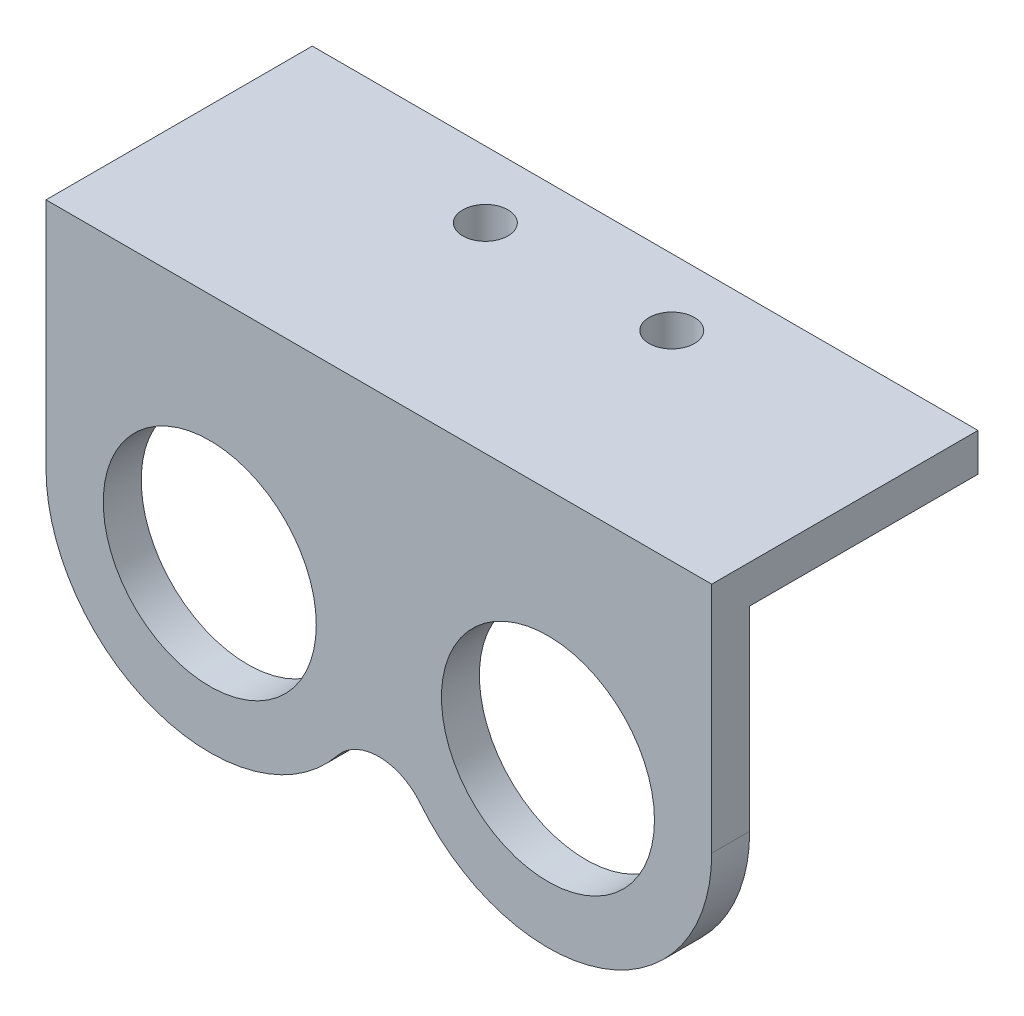
from build123d import *

# Parameters (mm, degrees)
SKETCH2_R           = 8
BOSS_EXTRUDE1_DEPTH = 2.85
SKETCH3_W           = 17.15
SKETCH3_H           = 2.85
BOSS_EXTRUDE2_DEPTH = 50
SKETCH4_R           = 1.7
CUT_EXTRUDE1_DEPTH  = 2.85


with BuildPart() as part:
    # Sketch2 → Boss-Extrude1 (new body)
    with BuildSketch(Plane.XY):
        with BuildLine():
            Line((-25, 17.5), (-25, 0))
            ThreePointArc((-25, 0), (-16.787403964, -11.60099689), (-3.116564417, -7.710237508))
            ThreePointArc((-3.116564417, -7.710237508), (0, -6.21763182), (3.116564417, -7.710237508))
            ThreePointArc((3.116564417, -7.710237508), (16.787403964, -11.60099689), (25, 0))
            Line((25, 0), (25, 17.5))
            Line((25, 17.5), (-25, 17.5))
        make_face()
        with Locations((12.7, 0)):
            Circle(SKETCH2_R, mode=Mode.SUBTRACT)
        with Locations((-12.7, 0)):
            Circle(SKETCH2_R, mode=Mode.SUBTRACT)
    extrude(amount=BOSS_EXTRUDE1_DEPTH)

    # Sketch3 → Boss-Extrude2 (add)
    with BuildSketch(Plane.ZY.offset(25)):
        with Locations((-8.575, 16.075)):
            Rectangle(SKETCH3_W, SKETCH3_H)
    extrude(amount=-BOSS_EXTRUDE2_DEPTH)

    # Sketch4 → Cut-Extrude1 (cut)
    with BuildSketch(Plane(origin=(0, 17.5, 0), x_dir=(1, 0, 0), z_dir=(0, 1, 0))):
        with Locations((-7, 12.15)):
            Circle(SKETCH4_R)
        with Locations((7, 12.15)):
            Circle(SKETCH4_R)
    extrude(amount=-CUT_EXTRUDE1_DEPTH, mode=Mode.SUBTRACT)


solid = part.part
